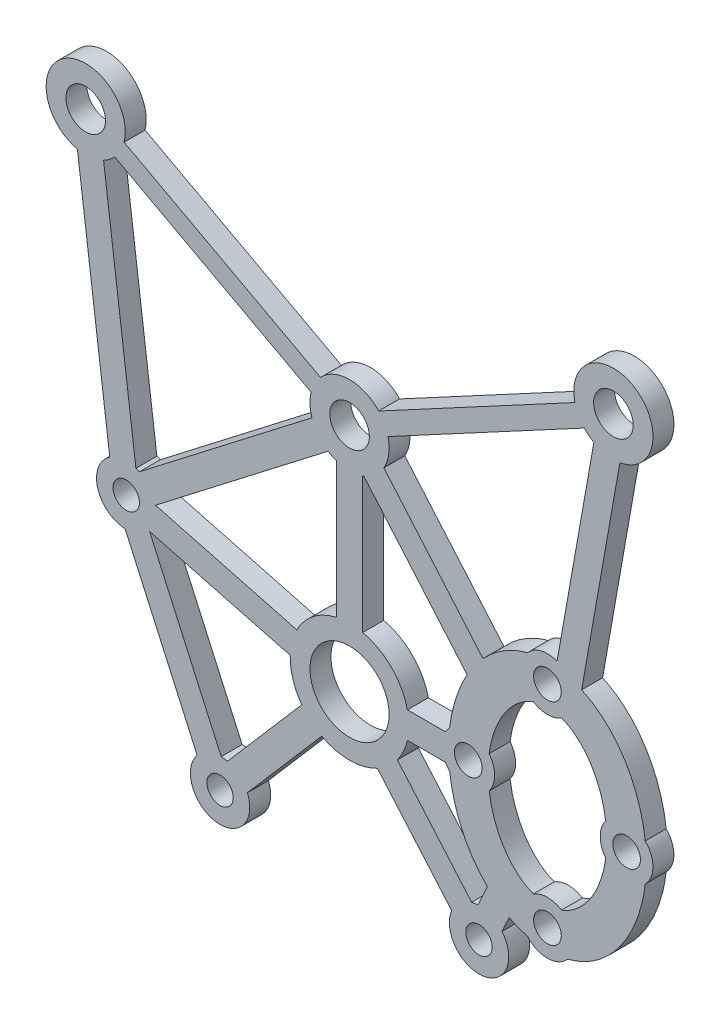
from build123d import *

# Parameters (mm, degrees)
SKETCH8_R           = 1
SKETCH8_R_2         = 1.500000001
SKETCH8_R_3         = 3
SKETCH8_R_4         = 1.5
SKETCH8_R_5         = 1.049999998
SKETCH8_R_6         = 1.05
BOSS_EXTRUDE1_DEPTH = 1.5875


with BuildPart() as part:
    # Sketch8 → Boss-Extrude1 (new body)
    with BuildSketch(Plane.XY):
        with BuildLine():
            Line((-13.086353998, -14.564609673), (1.796518672, -22.564153733))
            ThreePointArc((1.796518672, -22.564153733), (4.000000002, -21.6), (6.203481333, -22.564153733))
            Line((6.203481333, -22.564153733), (21.086354002, -14.564609673))
            ThreePointArc((21.086354002, -14.564609673), (25.651184859, -11.34528673), (24.491592476, -16.80944874))
            Line((24.491592476, -16.80944874), (21.594632818, -33.172177311))
            add(Edge.make_bspline(
                [(26.415943842, -40.678727885), (26.190074366, -38.784003898), (25.091906545, -35.832342913), (22.830851039, -33.788532272), (21.739107595, -33.238545613), (21.594632818, -33.172177311)],
                knots=[8.009475082, 8.009475082, 8.009475082, 8.009475082, 8.639379797, 9.032078879, 9.090955258, 9.090955258, 9.090955258, 9.090955258], degree=3))
            ThreePointArc((26.415943842, -40.678727885), (27.000000014, -42.091209061), (26.415943843, -43.503690238))
            add(Edge.make_bspline(
                [(20.516702098, -51.394901812), (21.03749091, -51.259926354), (22.533800563, -50.662395377), (25.091906547, -48.350075217), (26.190074368, -45.398414228), (26.415943843, -43.503690238)],
                knots=[6.474926491, 6.474926491, 6.474926491, 6.474926491, 6.675884389, 7.068583471, 7.698488187, 7.698488187, 7.698488187, 7.698488187], degree=3))
            ThreePointArc((20.516702098, -51.394901812), (19.000000019, -52.091209062), (17.483297936, -51.39490182))
            add(Edge.make_bspline(
                [(16.101578265, -50.861171127), (16.542577532, -51.091700443), (17.006966665, -51.271448649), (17.483297936, -51.39490182)],
                knots=[5.907641156, 5.907641156, 5.907641156, 5.907641156, 6.091444127, 6.091444127, 6.091444127, 6.091444127], degree=3))
            Line((16.101578265, -50.861171127), (15.561059424, -52.047023548))
            ThreePointArc((15.561059424, -52.047023548), (14.133861857, -55.693615173), (11.741313067, -52.593577485))
            Line((11.741313067, -52.593577485), (6.109164809, -46.066309546))
            ThreePointArc((6.109164809, -46.066309546), (4.000000002, -46.591209068), (1.890835194, -46.066309546))
            Line((1.890835194, -46.066309546), (-3.741313063, -52.593577485))
            ThreePointArc((-3.741313063, -52.593577485), (-6.139438128, -55.692810158), (-7.55392971, -52.038297803))
            Line((-7.55392971, -52.038297803), (-13.012969359, -39.900931113))
            ThreePointArc((-13.012969359, -39.900931113), (-15.09287941, -38.264638476), (-14.177523832, -35.78157513))
            Line((-14.177523832, -35.78157513), (-16.629703051, -16.783167924))
            ThreePointArc((-16.629703051, -16.783167924), (-17.592042406, -11.307284723), (-13.086353998, -14.564609673))
        make_face()
        with Locations((-12.927736722, -37.652546048)):
            Circle(SKETCH8_R, mode=Mode.SUBTRACT)
        with Locations((-15.999999999, -13.85)):
            Circle(SKETCH8_R_2, mode=Mode.SUBTRACT)
        with Locations((4.000000002, -42.091209068)):
            Circle(SKETCH8_R_3, mode=Mode.SUBTRACT)
        with Locations((4.000000002, -24.6)):
            Circle(SKETCH8_R_4, mode=Mode.SUBTRACT)
        with Locations((19.000000014, -34.091209062)):
            Circle(SKETCH8_R_5, mode=Mode.SUBTRACT)
        with Locations((25.000000014, -42.091209062)):
            Circle(SKETCH8_R_6, mode=Mode.SUBTRACT)
        with Locations((24.000000003, -13.85)):
            Circle(SKETCH8_R_4, mode=Mode.SUBTRACT)
        with Locations((19.000000014, -50.091209062)):
            Circle(SKETCH8_R_6, mode=Mode.SUBTRACT)
        with Locations((13.000000014, -42.091209062)):
            Circle(SKETCH8_R_5, mode=Mode.SUBTRACT)
        with Locations((13.815163294, -53.466300372)):
            Circle(SKETCH8_R, mode=Mode.SUBTRACT)
        with Locations((-5.81516329, -53.466300372)):
            Circle(SKETCH8_R, mode=Mode.SUBTRACT)
        with BuildLine():
            Line((-13.796518668, -15.885846268), (1.086354002, -23.885390328))
            ThreePointArc((1.086354002, -23.885390328), (1.002194363, -24.714722935), (1.149490441, -25.535197969))
            Line((1.149490441, -25.535197969), (-11.942202931, -35.629868826))
            ThreePointArc((-11.942202931, -35.629868826), (-12.066509782, -35.573895487), (-12.193978328, -35.52555319))
            Line((-12.193978328, -35.52555319), (-14.646157547, -16.527145984))
            ThreePointArc((-14.646157547, -16.527145984), (-14.192666478, -16.244482313), (-13.796518668, -15.885846268))
        make_face(mode=Mode.SUBTRACT)
        with BuildLine():
            Line((6.913646003, -23.885390328), (21.796518672, -15.885846268))
            ThreePointArc((21.796518672, -15.885846268), (22.137056458, -16.201476419), (22.522219684, -16.460778683))
            Line((22.522219684, -16.460778683), (19.730449721, -32.229370394))
            ThreePointArc((19.730449721, -32.229370394), (18.517890153, -32.150186115), (17.483297928, -32.787516314))
            add(Edge.make_bspline(
                [(17.483297928, -32.787516314), (16.962509109, -32.922491772), (15.727272297, -33.415766846), (14.665915712, -34.26639873), (14.116927694, -34.86100734)],
                knots=[3.333333835, 3.333333835, 3.333333835, 3.333333835, 3.534291735, 3.823410841, 3.823410841, 3.823410841, 3.823410841], degree=3))
            Line((14.116927694, -34.86100734), (6.60034411, -26.096065012))
            ThreePointArc((6.60034411, -26.096065012), (6.970318566, -25.020960368), (6.913646003, -23.885390328))
        make_face(mode=Mode.SUBTRACT)
        with BuildLine():
            Line((11.267949203, -41.091209067), (8.387482195, -41.091209067))
            ThreePointArc((8.387482195, -41.091209067), (7.181980517, -38.909228552), (5.000000002, -37.703726874))
            Line((5.000000002, -37.703726874), (5.000000002, -27.428427125))
            ThreePointArc((5.000000002, -27.428427125), (5.041188034, -27.41352581), (5.082154119, -27.398024744))
            Line((5.082154119, -27.398024744), (12.911091108, -36.527196283))
            add(Edge.make_bspline(
                [(12.911091108, -36.527196283), (12.211706609, -37.765848449), (11.760461262, -39.198939723), (11.584056161, -40.67872791)],
                knots=[4.064937043, 4.064937043, 4.064937043, 4.064937043, 4.556895536, 4.556895536, 4.556895536, 4.556895536], degree=3))
            ThreePointArc((11.584056161, -40.67872791), (11.412548353, -40.874657697), (11.267949203, -41.091209067))
        make_face(mode=Mode.SUBTRACT)
        with BuildLine():
            Line((11.267949213, -43.091209073), (8.387482194, -43.091209073))
            ThreePointArc((8.387482194, -43.091209073), (8.091394843, -43.964838767), (7.623388786, -44.759739322))
            Line((7.623388786, -44.759739322), (13.255537044, -51.287007261))
            ThreePointArc((13.255537044, -51.287007261), (13.496464731, -51.23898557), (13.741191761, -51.217516653))
            Line((13.741191761, -51.217516653), (14.450284347, -49.6618278))
            add(Edge.make_bspline(
                [(11.58405616, -43.503690213), (11.809925632, -45.398414212), (12.658784204, -47.679980557), (14.128913372, -49.352631306), (14.450284347, -49.6618278)],
                knots=[4.867882424, 4.867882424, 4.867882424, 4.867882424, 5.497787144, 5.65833174, 5.65833174, 5.65833174, 5.65833174], degree=3))
            ThreePointArc((11.58405616, -43.503690213), (11.412548358, -43.307760434), (11.267949213, -43.091209073))
        make_face(mode=Mode.SUBTRACT)
        with BuildLine():
            Line((-10.705156101, -37.20152807), (0, -40.029656258))
            ThreePointArc((0, -40.029656258), (1.242739245, -38.534874842), (3.000000002, -37.703726874))
            Line((3.000000002, -37.703726874), (3.000000002, -27.428427125))
            ThreePointArc((3.000000002, -27.428427125), (2.676302315, -27.292178381), (2.370745744, -27.119033657))
            Line((2.370745744, -27.119033657), (-10.705156101, -37.20152807))
        make_face(mode=Mode.SUBTRACT)
        with BuildLine():
            Line((-5.729930653, -51.217915307), (-11.15749378, -39.150532004))
            Line((-11.15749378, -39.150532004), (-0.497810837, -41.950860704))
            ThreePointArc((-0.497810837, -41.950860704), (-0.296617342, -43.428773795), (0.376611217, -44.759739322))
            Line((0.376611217, -44.759739322), (-5.255537039, -51.287007261))
            ThreePointArc((-5.255537039, -51.287007261), (-5.490888451, -51.239790585), (-5.729930653, -51.217915307))
        make_face(mode=Mode.SUBTRACT)
        with BuildLine():
            ThreePointArc((17.931899131, -35.782114294), (19.000000009, -36.091209062), (20.068100889, -35.782114299))
            add(Edge.make_bspline(
                [(23.417224995, -40.868579421), (23.351989797, -40.388373193), (23.059588765, -39.057302945), (22.112022209, -37.188969501), (20.925072461, -36.159009178), (20.236313774, -35.843572565), (20.068100889, -35.782114299)],
                knots=[8.033003045, 8.033003045, 8.033003045, 8.033003045, 8.246680716, 8.639379797, 9.032078879, 9.158456351, 9.158456351, 9.158456351, 9.158456351], degree=3))
            ThreePointArc((23.417224995, -40.868579421), (23.000000014, -42.091209063), (23.417224996, -43.313838704))
            add(Edge.make_bspline(
                [(20.068100897, -48.40030383), (20.23631378, -48.338845564), (20.925072464, -48.023408951), (22.112022209, -46.993448631), (23.059588765, -45.125115185), (23.351989798, -43.794044934), (23.417224996, -43.313838704)],
                knots=[6.549506919, 6.549506919, 6.549506919, 6.549506919, 6.675884389, 7.068583471, 7.461282552, 7.674960224, 7.674960224, 7.674960224, 7.674960224], degree=3))
            ThreePointArc((20.068100897, -48.40030383), (19.000000009, -48.091209062), (17.931899123, -48.400303835))
            add(Edge.make_bspline(
                [(14.582775013, -43.313838729), (14.648010212, -43.79404495), (14.940411244, -45.125115192), (15.887977797, -46.993448631), (17.074927547, -48.023408955), (17.763686236, -48.338845569), (17.931899123, -48.400303835)],
                knots=[4.891410394, 4.891410394, 4.891410394, 4.891410394, 5.105088062, 5.497787144, 5.890486225, 6.016863699, 6.016863699, 6.016863699, 6.016863699], degree=3))
            ThreePointArc((14.582775013, -43.313838729), (15.000000014, -42.091209063), (14.582775014, -40.868579396))
            add(Edge.make_bspline(
                [(17.931899131, -35.782114294), (17.763686241, -35.843572561), (17.07492755, -36.159009174), (15.887977797, -37.188969501), (14.940411245, -39.057302938), (14.648010213, -40.388373177), (14.582775014, -40.868579396)],
                knots=[9.691099567, 9.691099567, 9.691099567, 9.691099567, 9.817477042, 10.210176124, 10.602875206, 10.816552873, 10.816552873, 10.816552873, 10.816552873], degree=3))
        make_face(mode=Mode.SUBTRACT)
    extrude(amount=BOSS_EXTRUDE1_DEPTH)


solid = part.part
